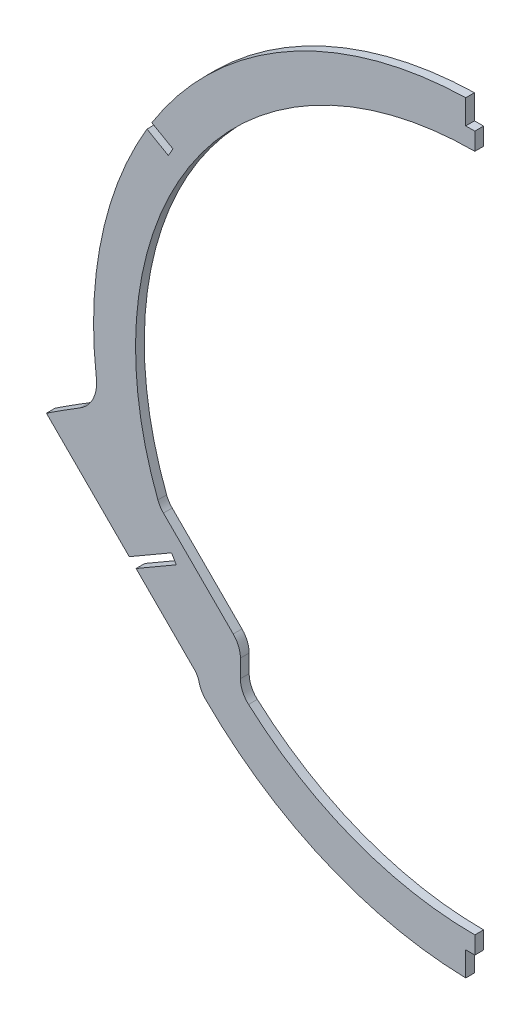
from build123d import *

# Parameters (mm, degrees)
BOSS_EXTRUDE1_DEPTH = 1.5875
CUT_EXTRUDE1_DEPTH  = 3.175
FILLET1_R           = 8.89
SKETCH4_W           = 218.524279389
SKETCH4_H           = 440.65456999
CUT_EXTRUDE3_DEPTH  = 139.43
BOSS_EXTRUDE2_DEPTH = 1.5875
FILLET2_R           = 12.7
FILLET3_R           = 6.35
SKETCH6_W           = 3.302
SKETCH6_H           = 12.7
CUT_EXTRUDE4_DEPTH  = 4.1750001


with BuildPart() as part:
    # Sketch1 → Boss-Extrude1 (new body, symmetric)
    with BuildSketch(Plane.XY):
        with BuildLine():
            Line((-127.293308919, -32.555250036), (-100.352540556, -59.496018399))
            Line((-100.352540556, -59.496018399), (-100.352540556, -73.509198709))
            ThreePointArc((-100.352540556, -73.509198709), (-79.006783461, -91.825666433), (-54.399250036, -105.449308919))
            ThreePointArc((-54.399250036, -105.449308919), (97.88479172, 119.72879172), (-127.293308919, -32.555250036))
        make_face()
    extrude(amount=BOSS_EXTRUDE1_DEPTH, both=True)

    # Sketch2 → Cut-Extrude1 (cut)
    with BuildSketch(Plane.XY.offset(1.5875)):
        with BuildLine():
            Line((-114.372852664, -23.923091601), (-85.112540556, -53.183403709))
            Line((-85.112540556, -53.183403709), (-85.112540556, -67.215707726))
            ThreePointArc((-85.112540556, -67.215707726), (102.064529488, 90.826663911), (-114.372852664, -23.923091601))
        make_face()
    extrude(amount=-CUT_EXTRUDE1_DEPTH, mode=Mode.SUBTRACT)

    # Fillet1
    fillet1_edges = [part.edges().sort_by_distance(p)[0] for p in [
        (-114.372852664, -23.923091601, 0),
        (-85.112540556, -67.215707726, 0),
        (-85.112540556, -53.183403709, 0),
        (-100.352540556, -73.509198709, -0.79375),
        (-100.352540556, -59.496018399, -0.79375),
        (-127.293308919, -32.555250036, -0.79375),
    ]]
    fillet(fillet1_edges, radius=FILLET1_R)

    # Sketch4 → Cut-Extrude3 (cut, through all)
    with BuildSketch(Plane(origin=(0, 0, 0), x_dir=(0, 0, -1), z_dir=(1, 0, 0))):
        with Locations((12.98164036, 12.468370851)):
            Rectangle(SKETCH4_W, SKETCH4_H)
    extrude(amount=CUT_EXTRUDE3_DEPTH, mode=Mode.SUBTRACT)

    # Sketch5 → Boss-Extrude2 (add, symmetric)
    with BuildSketch(Plane.XY):
        with BuildLine():
            Line((-100.344096462, -70.2778643), (-93.131982579, -63.067144592))
            Line((-93.131982579, -63.067144592), (-135.386236526, -2.54))
            ThreePointArc((-135.386236526, -2.54), (-145.549369809, -8.667691803), (-155.542666772, -15.068621483))
            Line((-155.542666772, -15.068621483), (-100.344096462, -70.2778643))
        make_face()
    extrude(amount=BOSS_EXTRUDE2_DEPTH, both=True)

    # Fillet2
    fillet2_edges = [part.edges().sort_by_distance(p)[0] for p in [
        (-136.181300165, -3.005917211, 0),
    ]]
    fillet(fillet2_edges, radius=FILLET2_R)

    # Fillet3
    fillet3_edges = [part.edges().sort_by_distance(p)[0] for p in [
        (-100.344096462, -70.2778643, -0.79375),
    ]]
    fillet(fillet3_edges, radius=FILLET3_R)

    # Sketch6 → Cut-Extrude4 (cut, through all)
    with BuildSketch(Plane(origin=(0, 0, -1.5875), x_dir=(-1, 0, 0), z_dir=(0, 0, -1))):
        with Locations((1.651, 157.734)):
            Rectangle(SKETCH6_W, SKETCH6_H)
        Polygon((109.598496198, 91.009030044), (111.278220029, 88.078029687), (122.297018363, 94.392780931), (120.617294532, 97.323781288), align=None)
        Polygon((108.408719805, -39.179754441), (110.102498062, -36.256853407), (126.58502269, -45.808234558), (124.891244433, -48.731135592), align=None)
        with Locations((1.651, -114.046)):
            Rectangle(SKETCH6_W, SKETCH6_H)
    extrude(amount=-CUT_EXTRUDE4_DEPTH, mode=Mode.SUBTRACT)


solid = part.part
